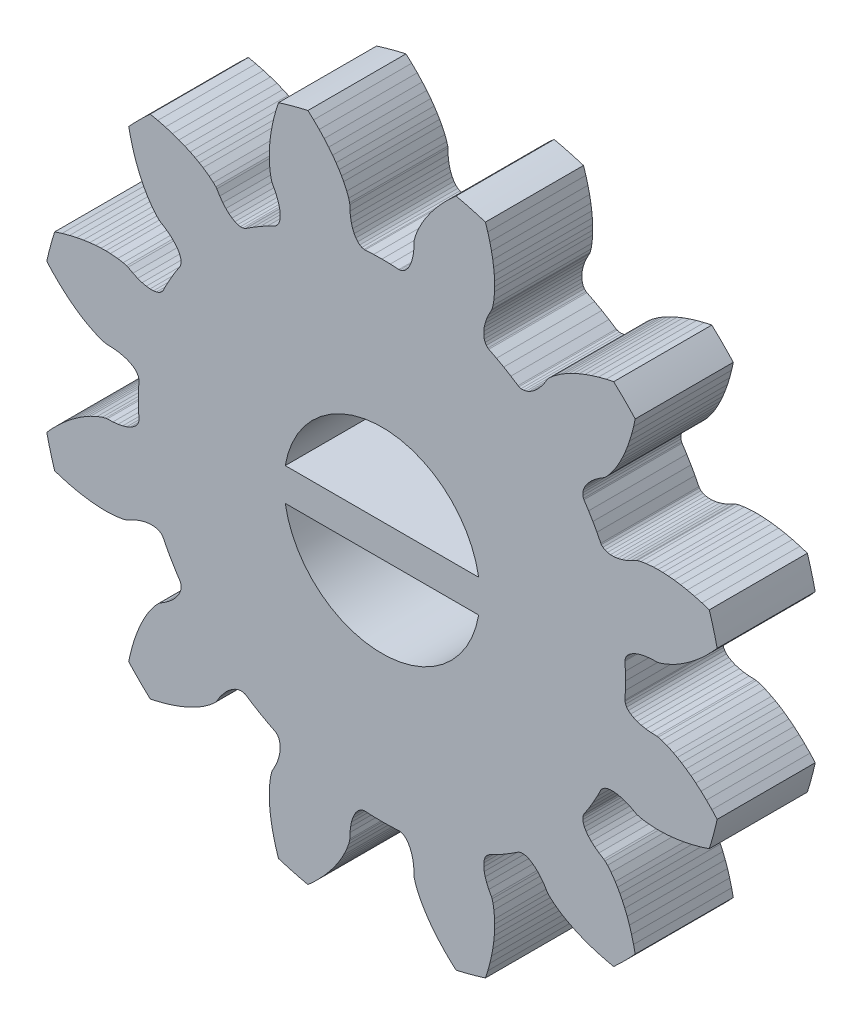
from build123d import *

# Parameters (mm, degrees)
DODANIE_WYCI_GNI_CIE1_DEPTH = 3


with BuildPart() as part:
    # szkic → Dodanie-wyciągnięcie1 (new body)
    with BuildSketch(Plane.XY):
        with BuildLine():
            Line((13.3041035, -6.8561363), (13.3646303, -6.6242917))
            Line((13.3646303, -6.6242917), (13.4304655, -6.4093816))
            Line((13.4304655, -6.4093816), (13.5002922, -6.2114851))
            Line((13.5002922, -6.2114851), (13.5727071, -6.0307313))
            Line((13.5727071, -6.0307313), (13.646359, -5.8670802))
            Line((13.646359, -5.8670802), (13.721124, -5.718017))
            Line((13.721124, -5.718017), (13.7934881, -5.5876952))
            Line((13.7934881, -5.5876952), (13.8641894, -5.4719934))
            Line((13.8641894, -5.4719934), (13.993399, -5.287051))
            Line((13.993399, -5.287051), (14.1005731, -5.157982))
            Line((14.1005731, -5.157982), (14.1765304, -5.080584))
            Line((14.1765304, -5.080584), (14.2152558, -5.0521983))
            Line((14.2152558, -5.0521983), (14.3621288, -4.9615699))
            Line((14.3621288, -4.9615699), (14.4896324, -4.8681526))
            Line((14.4896324, -4.8681526), (14.5978226, -4.7734035))
            Line((14.5978226, -4.7734035), (14.6868312, -4.6787708))
            Line((14.6868312, -4.6787708), (14.7568878, -4.5856924))
            Line((14.7568878, -4.5856924), (14.8083, -4.495561))
            Line((14.8083, -4.495561), (14.8414711, -4.409795))
            Line((14.8414711, -4.409795), (14.8568795, -4.3297232))
            Line((14.8568795, -4.3297232), (14.8550807, -4.2566876))
            Line((14.8550807, -4.2566876), (14.8367255, -4.1919755))
            Line((14.8367255, -4.1919755), (14.821549, -4.163129))
            Line((14.821549, -4.163129), (14.6787997, -3.9427598))
            Line((14.6787997, -3.9427598), (14.5481107, -3.725))
            Line((14.5481107, -3.725), (14.4248697, -3.5029402))
            Line((14.4248697, -3.5029402), (14.305399, -3.269131))
            Line((14.305399, -3.269131), (14.2880055, -3.2415645))
            Line((14.2880055, -3.2415645), (14.2411407, -3.1933124))
            Line((14.2411407, -3.1933124), (14.1787895, -3.1552368))
            Line((14.1787895, -3.1552368), (14.1017411, -3.128545))
            Line((14.1017411, -3.128545), (14.01088, -3.114389))
            Line((14.01088, -3.114389), (13.9071178, -3.1138476))
            Line((13.9071178, -3.1138476), (13.7914812, -3.1279792))
            Line((13.7914812, -3.1279792), (13.6650226, -3.1577465))
            Line((13.6650226, -3.1577465), (13.5288724, -3.2040674))
            Line((13.5288724, -3.2040674), (13.3842188, -3.2677801))
            Line((13.3842188, -3.2677801), (13.2322958, -3.3496617))
            Line((13.2322958, -3.3496617), (13.1883504, -3.369006))
            Line((13.1883504, -3.369006), (13.0833431, -3.396088))
            Line((13.0833431, -3.396088), (12.917979, -3.424369))
            Line((12.917979, -3.424369), (12.6932094, -3.4437966))
            Line((12.6932094, -3.4437966), (12.5576581, -3.4471748))
            Line((12.5576581, -3.4471748), (12.408614, -3.444683))
            Line((12.408614, -3.444683), (12.242139, -3.4348998))
            Line((12.242139, -3.4348998), (12.0635871, -3.4168587))
            Line((12.0635871, -3.4168587), (11.8708422, -3.3891949))
            Line((11.8708422, -3.3891949), (11.6645455, -3.3507184))
            Line((11.6645455, -3.3507184), (11.4455103, -3.3002783))
            Line((11.4455103, -3.3002783), (11.2144635, -3.2367737))
            Line((11.2144635, -3.2367737), (10.9882086, -3.1643386))
            ThreePointArc((10.9882086, -3.1643386), (10.857824593, -2.717587715), (10.747365, -2.2654981))
            Line((10.747365, -2.2654981), (10.90709, -2.08964))
            Line((10.90709, -2.08964), (11.07543, -1.91912))
            Line((11.07543, -1.91912), (11.2399, -1.76592))
            Line((11.2399, -1.76592), (11.39932, -1.62945))
            Line((11.39932, -1.62945), (11.55241, -1.50912))
            Line((11.55241, -1.50912), (11.69802, -1.40422))
            Line((11.69802, -1.40422), (11.8373, -1.31251))
            Line((11.8373, -1.31251), (11.96513, -1.23583))
            Line((11.96513, -1.23583), (12.08421, -1.17098))
            Line((12.08421, -1.17098), (12.28858, -1.07542))
            Line((12.28858, -1.07542), (12.44593, -1.01723))
            Line((12.44593, -1.01723), (12.55041, -0.98818))
            Line((12.55041, -0.98818), (12.59814, -0.98296))
            Line((12.59814, -0.98296), (12.77065, -0.97791))
            Line((12.77065, -0.97791), (12.92778, -0.96076))
            Line((12.92778, -0.96076), (13.06885, -0.9328))
            Line((13.06885, -0.9328), (13.19325, -0.89535))
            Line((13.19325, -0.89535), (13.30046, -0.84977))
            Line((13.30046, -0.84977), (13.39005, -0.79742))
            Line((13.39005, -0.79742), (13.46166, -0.73973))
            Line((13.46166, -0.73973), (13.51504, -0.67809))
            Line((13.51504, -0.67809), (13.55, -0.61394))
            Line((13.55, -0.61394), (13.56646, -0.54872))
            Line((13.56646, -0.54872), (13.56774, -0.51615))
            Line((13.56774, -0.51615), (13.5543, -0.25393))
            Line((13.5543, -0.25393), (13.55, 0))
            Line((13.55, 0), (13.5543, 0.25393))
            Line((13.5543, 0.25393), (13.56774, 0.51615))
            Line((13.56774, 0.51615), (13.56646, 0.54872))
            Line((13.56646, 0.54872), (13.55, 0.61394))
            Line((13.55, 0.61394), (13.51504, 0.67809))
            Line((13.51504, 0.67809), (13.46166, 0.73973))
            Line((13.46166, 0.73973), (13.39005, 0.79742))
            Line((13.39005, 0.79742), (13.30046, 0.84977))
            Line((13.30046, 0.84977), (13.19325, 0.89535))
            Line((13.19325, 0.89535), (13.06885, 0.9328))
            Line((13.06885, 0.9328), (12.92778, 0.96076))
            Line((12.92778, 0.96076), (12.77065, 0.97791))
            Line((12.77065, 0.97791), (12.59814, 0.98296))
            Line((12.59814, 0.98296), (12.55041, 0.98818))
            Line((12.55041, 0.98818), (12.44593, 1.01723))
            Line((12.44593, 1.01723), (12.28858, 1.07542))
            Line((12.28858, 1.07542), (12.08421, 1.17098))
            Line((12.08421, 1.17098), (11.96513, 1.23583))
            Line((11.96513, 1.23583), (11.8373, 1.31251))
            Line((11.8373, 1.31251), (11.69802, 1.40422))
            Line((11.69802, 1.40422), (11.55241, 1.50912))
            Line((11.55241, 1.50912), (11.39932, 1.62945))
            Line((11.39932, 1.62945), (11.2399, 1.76592))
            Line((11.2399, 1.76592), (11.07543, 1.91912))
            Line((11.07543, 1.91912), (10.90709, 2.08964))
            Line((10.90709, 2.08964), (10.747365, 2.2654981))
            ThreePointArc((10.747365, 2.2654981), (10.857824593, 2.717587715), (10.9882086, 3.1643386))
            Line((10.9882086, 3.1643386), (11.2144635, 3.2367737))
            Line((11.2144635, 3.2367737), (11.4455103, 3.3002783))
            Line((11.4455103, 3.3002783), (11.6645455, 3.3507184))
            Line((11.6645455, 3.3507184), (11.8708422, 3.3891949))
            Line((11.8708422, 3.3891949), (12.0635871, 3.4168587))
            Line((12.0635871, 3.4168587), (12.242139, 3.4348998))
            Line((12.242139, 3.4348998), (12.408614, 3.444683))
            Line((12.408614, 3.444683), (12.5576581, 3.4471748))
            Line((12.5576581, 3.4471748), (12.6932094, 3.4437966))
            Line((12.6932094, 3.4437966), (12.917979, 3.424369))
            Line((12.917979, 3.424369), (13.0833431, 3.396088))
            Line((13.0833431, 3.396088), (13.1883504, 3.369006))
            Line((13.1883504, 3.369006), (13.2322958, 3.3496617))
            Line((13.2322958, 3.3496617), (13.3842188, 3.2677801))
            Line((13.3842188, 3.2677801), (13.5288724, 3.2040674))
            Line((13.5288724, 3.2040674), (13.6650226, 3.1577465))
            Line((13.6650226, 3.1577465), (13.7914812, 3.1279792))
            Line((13.7914812, 3.1279792), (13.9071178, 3.1138476))
            Line((13.9071178, 3.1138476), (14.01088, 3.114389))
            Line((14.01088, 3.114389), (14.1017411, 3.128545))
            Line((14.1017411, 3.128545), (14.1787895, 3.1552368))
            Line((14.1787895, 3.1552368), (14.2411407, 3.1933124))
            Line((14.2411407, 3.1933124), (14.2880055, 3.2415645))
            Line((14.2880055, 3.2415645), (14.305399, 3.269131))
            Line((14.305399, 3.269131), (14.4248697, 3.5029402))
            Line((14.4248697, 3.5029402), (14.5481107, 3.725))
            Line((14.5481107, 3.725), (14.6787997, 3.9427598))
            Line((14.6787997, 3.9427598), (14.821549, 4.163129))
            Line((14.821549, 4.163129), (14.8367255, 4.1919755))
            Line((14.8367255, 4.1919755), (14.8550807, 4.2566876))
            Line((14.8550807, 4.2566876), (14.8568795, 4.3297232))
            Line((14.8568795, 4.3297232), (14.8414711, 4.409795))
            Line((14.8414711, 4.409795), (14.8083, 4.495561))
            Line((14.8083, 4.495561), (14.7568878, 4.5856924))
            Line((14.7568878, 4.5856924), (14.6868312, 4.6787708))
            Line((14.6868312, 4.6787708), (14.5978226, 4.7734035))
            Line((14.5978226, 4.7734035), (14.4896324, 4.8681526))
            Line((14.4896324, 4.8681526), (14.3621288, 4.9615699))
            Line((14.3621288, 4.9615699), (14.2152558, 5.0521983))
            Line((14.2152558, 5.0521983), (14.1765304, 5.080584))
            Line((14.1765304, 5.080584), (14.1005731, 5.157982))
            Line((14.1005731, 5.157982), (13.993399, 5.287051))
            Line((13.993399, 5.287051), (13.8641894, 5.4719934))
            Line((13.8641894, 5.4719934), (13.7934881, 5.5876952))
            Line((13.7934881, 5.5876952), (13.721124, 5.718017))
            Line((13.721124, 5.718017), (13.646359, 5.8670802))
            Line((13.646359, 5.8670802), (13.5727071, 6.0307313))
            Line((13.5727071, 6.0307313), (13.5002922, 6.2114851))
            Line((13.5002922, 6.2114851), (13.4304655, 6.4093816))
            Line((13.4304655, 6.4093816), (13.3646303, 6.6242917))
            Line((13.3646303, 6.6242917), (13.3041035, 6.8561363))
            Line((13.3041035, 6.8561363), (13.2537067, 7.0882964))
            ThreePointArc((13.2537067, 7.0882964), (13.575412309, 7.424587691), (13.9117036, 7.7462933))
            Line((13.9117036, 7.7462933), (14.1438637, 7.6958965))
            Line((14.1438637, 7.6958965), (14.3757083, 7.6353697))
            Line((14.3757083, 7.6353697), (14.5906184, 7.5695345))
            Line((14.5906184, 7.5695345), (14.7885149, 7.4997078))
            Line((14.7885149, 7.4997078), (14.9692687, 7.4272929))
            Line((14.9692687, 7.4272929), (15.1329198, 7.353641))
            Line((15.1329198, 7.353641), (15.281983, 7.278876))
            Line((15.281983, 7.278876), (15.4123048, 7.2065119))
            Line((15.4123048, 7.2065119), (15.5280066, 7.1358106))
            Line((15.5280066, 7.1358106), (15.712949, 7.006601))
            Line((15.712949, 7.006601), (15.842018, 6.8994269))
            Line((15.842018, 6.8994269), (15.919416, 6.8234696))
            Line((15.919416, 6.8234696), (15.9478017, 6.7847442))
            Line((15.9478017, 6.7847442), (16.0384301, 6.6378712))
            Line((16.0384301, 6.6378712), (16.1318474, 6.5103676))
            Line((16.1318474, 6.5103676), (16.2265965, 6.4021774))
            Line((16.2265965, 6.4021774), (16.3212292, 6.3131688))
            Line((16.3212292, 6.3131688), (16.4143076, 6.2431122))
            Line((16.4143076, 6.2431122), (16.504439, 6.1917))
            Line((16.504439, 6.1917), (16.590205, 6.1585289))
            Line((16.590205, 6.1585289), (16.6702768, 6.1431205))
            Line((16.6702768, 6.1431205), (16.7433124, 6.1449193))
            Line((16.7433124, 6.1449193), (16.8080245, 6.1632745))
            Line((16.8080245, 6.1632745), (16.836871, 6.178451))
            Line((16.836871, 6.178451), (17.0572402, 6.3212003))
            Line((17.0572402, 6.3212003), (17.275, 6.4518893))
            Line((17.275, 6.4518893), (17.4970598, 6.5751303))
            Line((17.4970598, 6.5751303), (17.730869, 6.694601))
            Line((17.730869, 6.694601), (17.7584355, 6.7119945))
            Line((17.7584355, 6.7119945), (17.8066876, 6.7588593))
            Line((17.8066876, 6.7588593), (17.8447632, 6.8212105))
            Line((17.8447632, 6.8212105), (17.871455, 6.8982589))
            Line((17.871455, 6.8982589), (17.885611, 6.98912))
            Line((17.885611, 6.98912), (17.8861524, 7.0928822))
            Line((17.8861524, 7.0928822), (17.8720208, 7.2085188))
            Line((17.8720208, 7.2085188), (17.8422535, 7.3349774))
            Line((17.8422535, 7.3349774), (17.7959326, 7.4711276))
            Line((17.7959326, 7.4711276), (17.7322199, 7.6157812))
            Line((17.7322199, 7.6157812), (17.6503383, 7.7677042))
            Line((17.6503383, 7.7677042), (17.630994, 7.8116496))
            Line((17.630994, 7.8116496), (17.603912, 7.9166569))
            Line((17.603912, 7.9166569), (17.575631, 8.082021))
            Line((17.575631, 8.082021), (17.5562034, 8.3067906))
            Line((17.5562034, 8.3067906), (17.5528252, 8.4423419))
            Line((17.5528252, 8.4423419), (17.555317, 8.591386))
            Line((17.555317, 8.591386), (17.5651002, 8.757861))
            Line((17.5651002, 8.757861), (17.5831413, 8.9364129))
            Line((17.5831413, 8.9364129), (17.6108051, 9.1291578))
            Line((17.6108051, 9.1291578), (17.6492816, 9.3354545))
            Line((17.6492816, 9.3354545), (17.6997217, 9.5544897))
            Line((17.6997217, 9.5544897), (17.7632263, 9.7855365))
            Line((17.7632263, 9.7855365), (17.8356614, 10.0117914))
            ThreePointArc((17.8356614, 10.0117914), (18.282412285, 10.142175407), (18.7345019, 10.252635))
            Line((18.7345019, 10.252635), (18.91036, 10.09291))
            Line((18.91036, 10.09291), (19.08088, 9.92457))
            Line((19.08088, 9.92457), (19.23408, 9.7601))
            Line((19.23408, 9.7601), (19.37055, 9.60068))
            Line((19.37055, 9.60068), (19.49088, 9.44759))
            Line((19.49088, 9.44759), (19.59578, 9.30198))
            Line((19.59578, 9.30198), (19.68749, 9.1627))
            Line((19.68749, 9.1627), (19.76417, 9.03487))
            Line((19.76417, 9.03487), (19.82902, 8.91579))
            Line((19.82902, 8.91579), (19.92458, 8.71142))
            Line((19.92458, 8.71142), (19.98277, 8.55407))
            Line((19.98277, 8.55407), (20.01182, 8.44959))
            Line((20.01182, 8.44959), (20.01704, 8.40186))
            Line((20.01704, 8.40186), (20.02209, 8.22935))
            Line((20.02209, 8.22935), (20.03924, 8.07222))
            Line((20.03924, 8.07222), (20.0672, 7.93115))
            Line((20.0672, 7.93115), (20.10465, 7.80675))
            Line((20.10465, 7.80675), (20.15023, 7.69954))
            Line((20.15023, 7.69954), (20.20258, 7.60995))
            Line((20.20258, 7.60995), (20.26027, 7.53834))
            Line((20.26027, 7.53834), (20.32191, 7.48496))
            Line((20.32191, 7.48496), (20.38606, 7.45))
            Line((20.38606, 7.45), (20.45128, 7.43354))
            Line((20.45128, 7.43354), (20.48385, 7.43226))
            Line((20.48385, 7.43226), (20.74607, 7.4457))
            Line((20.74607, 7.4457), (21, 7.45))
            Line((21, 7.45), (21.25393, 7.4457))
            Line((21.25393, 7.4457), (21.51615, 7.43226))
            Line((21.51615, 7.43226), (21.54872, 7.43354))
            Line((21.54872, 7.43354), (21.61394, 7.45))
            Line((21.61394, 7.45), (21.67809, 7.48496))
            Line((21.67809, 7.48496), (21.73973, 7.53834))
            Line((21.73973, 7.53834), (21.79742, 7.60995))
            Line((21.79742, 7.60995), (21.84977, 7.69954))
            Line((21.84977, 7.69954), (21.89535, 7.80675))
            Line((21.89535, 7.80675), (21.9328, 7.93115))
            Line((21.9328, 7.93115), (21.96076, 8.07222))
            Line((21.96076, 8.07222), (21.97791, 8.22935))
            Line((21.97791, 8.22935), (21.98296, 8.40186))
            Line((21.98296, 8.40186), (21.98818, 8.44959))
            Line((21.98818, 8.44959), (22.01723, 8.55407))
            Line((22.01723, 8.55407), (22.07542, 8.71142))
            Line((22.07542, 8.71142), (22.17098, 8.91579))
            Line((22.17098, 8.91579), (22.23583, 9.03487))
            Line((22.23583, 9.03487), (22.31251, 9.1627))
            Line((22.31251, 9.1627), (22.40422, 9.30198))
            Line((22.40422, 9.30198), (22.50912, 9.44759))
            Line((22.50912, 9.44759), (22.62945, 9.60068))
            Line((22.62945, 9.60068), (22.76592, 9.7601))
            Line((22.76592, 9.7601), (22.91912, 9.92457))
            Line((22.91912, 9.92457), (23.08964, 10.09291))
            Line((23.08964, 10.09291), (23.2654981, 10.252635))
            ThreePointArc((23.2654981, 10.252635), (23.717587715, 10.142175407), (24.1643386, 10.0117914))
            Line((24.1643386, 10.0117914), (24.2367737, 9.7855365))
            Line((24.2367737, 9.7855365), (24.3002783, 9.5544897))
            Line((24.3002783, 9.5544897), (24.3507184, 9.3354545))
            Line((24.3507184, 9.3354545), (24.3891949, 9.1291578))
            Line((24.3891949, 9.1291578), (24.4168587, 8.9364129))
            Line((24.4168587, 8.9364129), (24.4348998, 8.757861))
            Line((24.4348998, 8.757861), (24.444683, 8.591386))
            Line((24.444683, 8.591386), (24.4471748, 8.4423419))
            Line((24.4471748, 8.4423419), (24.4437966, 8.3067906))
            Line((24.4437966, 8.3067906), (24.424369, 8.082021))
            Line((24.424369, 8.082021), (24.396088, 7.9166569))
            Line((24.396088, 7.9166569), (24.369006, 7.8116496))
            Line((24.369006, 7.8116496), (24.3496617, 7.7677042))
            Line((24.3496617, 7.7677042), (24.2677801, 7.6157812))
            Line((24.2677801, 7.6157812), (24.2040674, 7.4711276))
            Line((24.2040674, 7.4711276), (24.1577465, 7.3349774))
            Line((24.1577465, 7.3349774), (24.1279792, 7.2085188))
            Line((24.1279792, 7.2085188), (24.1138476, 7.0928822))
            Line((24.1138476, 7.0928822), (24.114389, 6.98912))
            Line((24.114389, 6.98912), (24.128545, 6.8982589))
            Line((24.128545, 6.8982589), (24.1552368, 6.8212105))
            Line((24.1552368, 6.8212105), (24.1933124, 6.7588593))
            Line((24.1933124, 6.7588593), (24.2415645, 6.7119945))
            Line((24.2415645, 6.7119945), (24.269131, 6.694601))
            Line((24.269131, 6.694601), (24.5029402, 6.5751303))
            Line((24.5029402, 6.5751303), (24.725, 6.4518893))
            Line((24.725, 6.4518893), (24.9427598, 6.3212003))
            Line((24.9427598, 6.3212003), (25.163129, 6.178451))
            Line((25.163129, 6.178451), (25.1919755, 6.1632745))
            Line((25.1919755, 6.1632745), (25.2566876, 6.1449193))
            Line((25.2566876, 6.1449193), (25.3297232, 6.1431205))
            Line((25.3297232, 6.1431205), (25.409795, 6.1585289))
            Line((25.409795, 6.1585289), (25.495561, 6.1917))
            Line((25.495561, 6.1917), (25.5856924, 6.2431122))
            Line((25.5856924, 6.2431122), (25.6787708, 6.3131688))
            Line((25.6787708, 6.3131688), (25.7734035, 6.4021774))
            Line((25.7734035, 6.4021774), (25.8681526, 6.5103676))
            Line((25.8681526, 6.5103676), (25.9615699, 6.6378712))
            Line((25.9615699, 6.6378712), (26.0521983, 6.7847442))
            Line((26.0521983, 6.7847442), (26.080584, 6.8234696))
            Line((26.080584, 6.8234696), (26.157982, 6.8994269))
            Line((26.157982, 6.8994269), (26.287051, 7.006601))
            Line((26.287051, 7.006601), (26.4719934, 7.1358106))
            Line((26.4719934, 7.1358106), (26.5876952, 7.2065119))
            Line((26.5876952, 7.2065119), (26.718017, 7.278876))
            Line((26.718017, 7.278876), (26.8670802, 7.353641))
            Line((26.8670802, 7.353641), (27.0307313, 7.4272929))
            Line((27.0307313, 7.4272929), (27.2114851, 7.4997078))
            Line((27.2114851, 7.4997078), (27.4093816, 7.5695345))
            Line((27.4093816, 7.5695345), (27.6242917, 7.6353697))
            Line((27.6242917, 7.6353697), (27.8561363, 7.6958965))
            Line((27.8561363, 7.6958965), (28.0882964, 7.7462933))
            ThreePointArc((28.0882964, 7.7462933), (28.424587691, 7.424587691), (28.7462933, 7.0882964))
            Line((28.7462933, 7.0882964), (28.6958965, 6.8561363))
            Line((28.6958965, 6.8561363), (28.6353697, 6.6242917))
            Line((28.6353697, 6.6242917), (28.5695345, 6.4093816))
            Line((28.5695345, 6.4093816), (28.4997078, 6.2114851))
            Line((28.4997078, 6.2114851), (28.4272929, 6.0307313))
            Line((28.4272929, 6.0307313), (28.353641, 5.8670802))
            Line((28.353641, 5.8670802), (28.278876, 5.718017))
            Line((28.278876, 5.718017), (28.2065119, 5.5876952))
            Line((28.2065119, 5.5876952), (28.1358106, 5.4719934))
            Line((28.1358106, 5.4719934), (28.006601, 5.287051))
            Line((28.006601, 5.287051), (27.8994269, 5.157982))
            Line((27.8994269, 5.157982), (27.8234696, 5.080584))
            Line((27.8234696, 5.080584), (27.7847442, 5.0521983))
            Line((27.7847442, 5.0521983), (27.6378712, 4.9615699))
            Line((27.6378712, 4.9615699), (27.5103676, 4.8681526))
            Line((27.5103676, 4.8681526), (27.4021774, 4.7734035))
            Line((27.4021774, 4.7734035), (27.3131688, 4.6787708))
            Line((27.3131688, 4.6787708), (27.2431122, 4.5856924))
            Line((27.2431122, 4.5856924), (27.1917, 4.495561))
            Line((27.1917, 4.495561), (27.1585289, 4.409795))
            Line((27.1585289, 4.409795), (27.1431205, 4.3297232))
            Line((27.1431205, 4.3297232), (27.1449193, 4.2566876))
            Line((27.1449193, 4.2566876), (27.1632745, 4.1919755))
            Line((27.1632745, 4.1919755), (27.178451, 4.163129))
            Line((27.178451, 4.163129), (27.3212003, 3.9427598))
            Line((27.3212003, 3.9427598), (27.4518893, 3.725))
            Line((27.4518893, 3.725), (27.5751303, 3.5029402))
            Line((27.5751303, 3.5029402), (27.694601, 3.269131))
            Line((27.694601, 3.269131), (27.7119945, 3.2415645))
            Line((27.7119945, 3.2415645), (27.7588593, 3.1933124))
            Line((27.7588593, 3.1933124), (27.8212105, 3.1552368))
            Line((27.8212105, 3.1552368), (27.8982589, 3.128545))
            Line((27.8982589, 3.128545), (27.98912, 3.114389))
            Line((27.98912, 3.114389), (28.0928822, 3.1138476))
            Line((28.0928822, 3.1138476), (28.2085188, 3.1279792))
            Line((28.2085188, 3.1279792), (28.3349774, 3.1577465))
            Line((28.3349774, 3.1577465), (28.4711276, 3.2040674))
            Line((28.4711276, 3.2040674), (28.6157812, 3.2677801))
            Line((28.6157812, 3.2677801), (28.7677042, 3.3496617))
            Line((28.7677042, 3.3496617), (28.8116496, 3.369006))
            Line((28.8116496, 3.369006), (28.9166569, 3.396088))
            Line((28.9166569, 3.396088), (29.082021, 3.424369))
            Line((29.082021, 3.424369), (29.3067906, 3.4437966))
            Line((29.3067906, 3.4437966), (29.4423419, 3.4471748))
            Line((29.4423419, 3.4471748), (29.591386, 3.444683))
            Line((29.591386, 3.444683), (29.757861, 3.4348998))
            Line((29.757861, 3.4348998), (29.9364129, 3.4168587))
            Line((29.9364129, 3.4168587), (30.1291578, 3.3891949))
            Line((30.1291578, 3.3891949), (30.3354545, 3.3507184))
            Line((30.3354545, 3.3507184), (30.5544897, 3.3002783))
            Line((30.5544897, 3.3002783), (30.7855365, 3.2367737))
            Line((30.7855365, 3.2367737), (31.0117914, 3.1643386))
            ThreePointArc((31.0117914, 3.1643386), (31.142175407, 2.717587715), (31.252635, 2.2654981))
            Line((31.252635, 2.2654981), (31.09291, 2.08964))
            Line((31.09291, 2.08964), (30.92457, 1.91912))
            Line((30.92457, 1.91912), (30.7601, 1.76592))
            Line((30.7601, 1.76592), (30.60068, 1.62945))
            Line((30.60068, 1.62945), (30.44759, 1.50912))
            Line((30.44759, 1.50912), (30.30198, 1.40422))
            Line((30.30198, 1.40422), (30.1627, 1.31251))
            Line((30.1627, 1.31251), (30.03487, 1.23583))
            Line((30.03487, 1.23583), (29.91579, 1.17098))
            Line((29.91579, 1.17098), (29.71142, 1.07542))
            Line((29.71142, 1.07542), (29.55407, 1.01723))
            Line((29.55407, 1.01723), (29.44959, 0.98818))
            Line((29.44959, 0.98818), (29.40186, 0.98296))
            Line((29.40186, 0.98296), (29.22935, 0.97791))
            Line((29.22935, 0.97791), (29.07222, 0.96076))
            Line((29.07222, 0.96076), (28.93115, 0.9328))
            Line((28.93115, 0.9328), (28.80675, 0.89535))
            Line((28.80675, 0.89535), (28.69954, 0.84977))
            Line((28.69954, 0.84977), (28.60995, 0.79742))
            Line((28.60995, 0.79742), (28.53834, 0.73973))
            Line((28.53834, 0.73973), (28.48496, 0.67809))
            Line((28.48496, 0.67809), (28.45, 0.61394))
            Line((28.45, 0.61394), (28.43354, 0.54872))
            Line((28.43354, 0.54872), (28.43226, 0.51615))
            Line((28.43226, 0.51615), (28.4457, 0.25393))
            Line((28.4457, 0.25393), (28.45, 0))
            Line((28.45, 0), (28.4457, -0.25393))
            Line((28.4457, -0.25393), (28.43226, -0.51615))
            Line((28.43226, -0.51615), (28.43354, -0.54872))
            Line((28.43354, -0.54872), (28.45, -0.61394))
            Line((28.45, -0.61394), (28.48496, -0.67809))
            Line((28.48496, -0.67809), (28.53834, -0.73973))
            Line((28.53834, -0.73973), (28.60995, -0.79742))
            Line((28.60995, -0.79742), (28.69954, -0.84977))
            Line((28.69954, -0.84977), (28.80675, -0.89535))
            Line((28.80675, -0.89535), (28.93115, -0.9328))
            Line((28.93115, -0.9328), (29.07222, -0.96076))
            Line((29.07222, -0.96076), (29.22935, -0.97791))
            Line((29.22935, -0.97791), (29.40186, -0.98296))
            Line((29.40186, -0.98296), (29.44959, -0.98818))
            Line((29.44959, -0.98818), (29.55407, -1.01723))
            Line((29.55407, -1.01723), (29.71142, -1.07542))
            Line((29.71142, -1.07542), (29.91579, -1.17098))
            Line((29.91579, -1.17098), (30.03487, -1.23583))
            Line((30.03487, -1.23583), (30.1627, -1.31251))
            Line((30.1627, -1.31251), (30.30198, -1.40422))
            Line((30.30198, -1.40422), (30.44759, -1.50912))
            Line((30.44759, -1.50912), (30.60068, -1.62945))
            Line((30.60068, -1.62945), (30.7601, -1.76592))
            Line((30.7601, -1.76592), (30.92457, -1.91912))
            Line((30.92457, -1.91912), (31.09291, -2.08964))
            Line((31.09291, -2.08964), (31.252635, -2.2654981))
            ThreePointArc((31.252635, -2.2654981), (31.142175407, -2.717587715), (31.0117914, -3.1643386))
            Line((31.0117914, -3.1643386), (30.7855365, -3.2367737))
            Line((30.7855365, -3.2367737), (30.5544897, -3.3002783))
            Line((30.5544897, -3.3002783), (30.3354545, -3.3507184))
            Line((30.3354545, -3.3507184), (30.1291578, -3.3891949))
            Line((30.1291578, -3.3891949), (29.9364129, -3.4168587))
            Line((29.9364129, -3.4168587), (29.757861, -3.4348998))
            Line((29.757861, -3.4348998), (29.591386, -3.444683))
            Line((29.591386, -3.444683), (29.4423419, -3.4471748))
            Line((29.4423419, -3.4471748), (29.3067906, -3.4437966))
            Line((29.3067906, -3.4437966), (29.082021, -3.424369))
            Line((29.082021, -3.424369), (28.9166569, -3.396088))
            Line((28.9166569, -3.396088), (28.8116496, -3.369006))
            Line((28.8116496, -3.369006), (28.7677042, -3.3496617))
            Line((28.7677042, -3.3496617), (28.6157812, -3.2677801))
            Line((28.6157812, -3.2677801), (28.4711276, -3.2040674))
            Line((28.4711276, -3.2040674), (28.3349774, -3.1577465))
            Line((28.3349774, -3.1577465), (28.2085188, -3.1279792))
            Line((28.2085188, -3.1279792), (28.0928822, -3.1138476))
            Line((28.0928822, -3.1138476), (27.98912, -3.114389))
            Line((27.98912, -3.114389), (27.8982589, -3.128545))
            Line((27.8982589, -3.128545), (27.8212105, -3.1552368))
            Line((27.8212105, -3.1552368), (27.7588593, -3.1933124))
            Line((27.7588593, -3.1933124), (27.7119945, -3.2415645))
            Line((27.7119945, -3.2415645), (27.694601, -3.269131))
            Line((27.694601, -3.269131), (27.5751303, -3.5029402))
            Line((27.5751303, -3.5029402), (27.4518893, -3.725))
            Line((27.4518893, -3.725), (27.3212003, -3.9427598))
            Line((27.3212003, -3.9427598), (27.178451, -4.163129))
            Line((27.178451, -4.163129), (27.1632745, -4.1919755))
            Line((27.1632745, -4.1919755), (27.1449193, -4.2566876))
            Line((27.1449193, -4.2566876), (27.1431205, -4.3297232))
            Line((27.1431205, -4.3297232), (27.1585289, -4.409795))
            Line((27.1585289, -4.409795), (27.1917, -4.495561))
            Line((27.1917, -4.495561), (27.2431122, -4.5856924))
            Line((27.2431122, -4.5856924), (27.3131688, -4.6787708))
            Line((27.3131688, -4.6787708), (27.4021774, -4.7734035))
            Line((27.4021774, -4.7734035), (27.5103676, -4.8681526))
            Line((27.5103676, -4.8681526), (27.6378712, -4.9615699))
            Line((27.6378712, -4.9615699), (27.7847442, -5.0521983))
            Line((27.7847442, -5.0521983), (27.8234696, -5.080584))
            Line((27.8234696, -5.080584), (27.8994269, -5.157982))
            Line((27.8994269, -5.157982), (28.006601, -5.287051))
            Line((28.006601, -5.287051), (28.1358106, -5.4719934))
            Line((28.1358106, -5.4719934), (28.2065119, -5.5876952))
            Line((28.2065119, -5.5876952), (28.278876, -5.718017))
            Line((28.278876, -5.718017), (28.353641, -5.8670802))
            Line((28.353641, -5.8670802), (28.4272929, -6.0307313))
            Line((28.4272929, -6.0307313), (28.4997078, -6.2114851))
            Line((28.4997078, -6.2114851), (28.5695345, -6.4093816))
            Line((28.5695345, -6.4093816), (28.6353697, -6.6242917))
            Line((28.6353697, -6.6242917), (28.6958965, -6.8561363))
            Line((28.6958965, -6.8561363), (28.7462933, -7.0882964))
            ThreePointArc((28.7462933, -7.0882964), (28.424587691, -7.424587691), (28.0882964, -7.7462933))
            Line((28.0882964, -7.7462933), (27.8561363, -7.6958965))
            Line((27.8561363, -7.6958965), (27.6242917, -7.6353697))
            Line((27.6242917, -7.6353697), (27.4093816, -7.5695345))
            Line((27.4093816, -7.5695345), (27.2114851, -7.4997078))
            Line((27.2114851, -7.4997078), (27.0307313, -7.4272929))
            Line((27.0307313, -7.4272929), (26.8670802, -7.353641))
            Line((26.8670802, -7.353641), (26.718017, -7.278876))
            Line((26.718017, -7.278876), (26.5876952, -7.2065119))
            Line((26.5876952, -7.2065119), (26.4719934, -7.1358106))
            Line((26.4719934, -7.1358106), (26.287051, -7.006601))
            Line((26.287051, -7.006601), (26.157982, -6.8994269))
            Line((26.157982, -6.8994269), (26.080584, -6.8234696))
            Line((26.080584, -6.8234696), (26.0521983, -6.7847442))
            Line((26.0521983, -6.7847442), (25.9615699, -6.6378712))
            Line((25.9615699, -6.6378712), (25.8681526, -6.5103676))
            Line((25.8681526, -6.5103676), (25.7734035, -6.4021774))
            Line((25.7734035, -6.4021774), (25.6787708, -6.3131688))
            Line((25.6787708, -6.3131688), (25.5856924, -6.2431122))
            Line((25.5856924, -6.2431122), (25.495561, -6.1917))
            Line((25.495561, -6.1917), (25.409795, -6.1585289))
            Line((25.409795, -6.1585289), (25.3297232, -6.1431205))
            Line((25.3297232, -6.1431205), (25.2566876, -6.1449193))
            Line((25.2566876, -6.1449193), (25.1919755, -6.1632745))
            Line((25.1919755, -6.1632745), (25.163129, -6.178451))
            Line((25.163129, -6.178451), (24.9427598, -6.3212003))
            Line((24.9427598, -6.3212003), (24.725, -6.4518893))
            Line((24.725, -6.4518893), (24.5029402, -6.5751303))
            Line((24.5029402, -6.5751303), (24.269131, -6.694601))
            Line((24.269131, -6.694601), (24.2415645, -6.7119945))
            Line((24.2415645, -6.7119945), (24.1933124, -6.7588593))
            Line((24.1933124, -6.7588593), (24.1552368, -6.8212105))
            Line((24.1552368, -6.8212105), (24.128545, -6.8982589))
            Line((24.128545, -6.8982589), (24.114389, -6.98912))
            Line((24.114389, -6.98912), (24.1138476, -7.0928822))
            Line((24.1138476, -7.0928822), (24.1279792, -7.2085188))
            Line((24.1279792, -7.2085188), (24.1577465, -7.3349774))
            Line((24.1577465, -7.3349774), (24.2040674, -7.4711276))
            Line((24.2040674, -7.4711276), (24.2677801, -7.6157812))
            Line((24.2677801, -7.6157812), (24.3496617, -7.7677042))
            Line((24.3496617, -7.7677042), (24.369006, -7.8116496))
            Line((24.369006, -7.8116496), (24.396088, -7.9166569))
            Line((24.396088, -7.9166569), (24.424369, -8.082021))
            Line((24.424369, -8.082021), (24.4437966, -8.3067906))
            Line((24.4437966, -8.3067906), (24.4471748, -8.4423419))
            Line((24.4471748, -8.4423419), (24.444683, -8.591386))
            Line((24.444683, -8.591386), (24.4348998, -8.757861))
            Line((24.4348998, -8.757861), (24.4168587, -8.9364129))
            Line((24.4168587, -8.9364129), (24.3891949, -9.1291578))
            Line((24.3891949, -9.1291578), (24.3507184, -9.3354545))
            Line((24.3507184, -9.3354545), (24.3002783, -9.5544897))
            Line((24.3002783, -9.5544897), (24.2367737, -9.7855365))
            Line((24.2367737, -9.7855365), (24.1643386, -10.0117914))
            ThreePointArc((24.1643386, -10.0117914), (23.717587715, -10.142175407), (23.2654981, -10.252635))
            Line((23.2654981, -10.252635), (23.08964, -10.09291))
            Line((23.08964, -10.09291), (22.91912, -9.92457))
            Line((22.91912, -9.92457), (22.76592, -9.7601))
            Line((22.76592, -9.7601), (22.62945, -9.60068))
            Line((22.62945, -9.60068), (22.50912, -9.44759))
            Line((22.50912, -9.44759), (22.40422, -9.30198))
            Line((22.40422, -9.30198), (22.31251, -9.1627))
            Line((22.31251, -9.1627), (22.23583, -9.03487))
            Line((22.23583, -9.03487), (22.17098, -8.91579))
            Line((22.17098, -8.91579), (22.07542, -8.71142))
            Line((22.07542, -8.71142), (22.01723, -8.55407))
            Line((22.01723, -8.55407), (21.98818, -8.44959))
            Line((21.98818, -8.44959), (21.98296, -8.40186))
            Line((21.98296, -8.40186), (21.97791, -8.22935))
            Line((21.97791, -8.22935), (21.96076, -8.07222))
            Line((21.96076, -8.07222), (21.9328, -7.93115))
            Line((21.9328, -7.93115), (21.89535, -7.80675))
            Line((21.89535, -7.80675), (21.84977, -7.69954))
            Line((21.84977, -7.69954), (21.79742, -7.60995))
            Line((21.79742, -7.60995), (21.73973, -7.53834))
            Line((21.73973, -7.53834), (21.67809, -7.48496))
            Line((21.67809, -7.48496), (21.61394, -7.45))
            Line((21.61394, -7.45), (21.54872, -7.43354))
            Line((21.54872, -7.43354), (21.51615, -7.43226))
            Line((21.51615, -7.43226), (21.25393, -7.4457))
            Line((21.25393, -7.4457), (21, -7.45))
            Line((21, -7.45), (20.74607, -7.4457))
            Line((20.74607, -7.4457), (20.48385, -7.43226))
            Line((20.48385, -7.43226), (20.45128, -7.43354))
            Line((20.45128, -7.43354), (20.38606, -7.45))
            Line((20.38606, -7.45), (20.32191, -7.48496))
            Line((20.32191, -7.48496), (20.26027, -7.53834))
            Line((20.26027, -7.53834), (20.20258, -7.60995))
            Line((20.20258, -7.60995), (20.15023, -7.69954))
            Line((20.15023, -7.69954), (20.10465, -7.80675))
            Line((20.10465, -7.80675), (20.0672, -7.93115))
            Line((20.0672, -7.93115), (20.03924, -8.07222))
            Line((20.03924, -8.07222), (20.02209, -8.22935))
            Line((20.02209, -8.22935), (20.01704, -8.40186))
            Line((20.01704, -8.40186), (20.01182, -8.44959))
            Line((20.01182, -8.44959), (19.98277, -8.55407))
            Line((19.98277, -8.55407), (19.92458, -8.71142))
            Line((19.92458, -8.71142), (19.82902, -8.91579))
            Line((19.82902, -8.91579), (19.76417, -9.03487))
            Line((19.76417, -9.03487), (19.68749, -9.1627))
            Line((19.68749, -9.1627), (19.59578, -9.30198))
            Line((19.59578, -9.30198), (19.49088, -9.44759))
            Line((19.49088, -9.44759), (19.37055, -9.60068))
            Line((19.37055, -9.60068), (19.23408, -9.7601))
            Line((19.23408, -9.7601), (19.08088, -9.92457))
            Line((19.08088, -9.92457), (18.91036, -10.09291))
            Line((18.91036, -10.09291), (18.7345019, -10.252635))
            ThreePointArc((18.7345019, -10.252635), (18.282412285, -10.142175407), (17.8356614, -10.0117914))
            Line((17.8356614, -10.0117914), (17.7632263, -9.7855365))
            Line((17.7632263, -9.7855365), (17.6997217, -9.5544897))
            Line((17.6997217, -9.5544897), (17.6492816, -9.3354545))
            Line((17.6492816, -9.3354545), (17.6108051, -9.1291578))
            Line((17.6108051, -9.1291578), (17.5831413, -8.9364129))
            Line((17.5831413, -8.9364129), (17.5651002, -8.757861))
            Line((17.5651002, -8.757861), (17.555317, -8.591386))
            Line((17.555317, -8.591386), (17.5528252, -8.4423419))
            Line((17.5528252, -8.4423419), (17.5562034, -8.3067906))
            Line((17.5562034, -8.3067906), (17.575631, -8.082021))
            Line((17.575631, -8.082021), (17.603912, -7.9166569))
            Line((17.603912, -7.9166569), (17.630994, -7.8116496))
            Line((17.630994, -7.8116496), (17.6503383, -7.7677042))
            Line((17.6503383, -7.7677042), (17.7322199, -7.6157812))
            Line((17.7322199, -7.6157812), (17.7959326, -7.4711276))
            Line((17.7959326, -7.4711276), (17.8422535, -7.3349774))
            Line((17.8422535, -7.3349774), (17.8720208, -7.2085188))
            Line((17.8720208, -7.2085188), (17.8861524, -7.0928822))
            Line((17.8861524, -7.0928822), (17.885611, -6.98912))
            Line((17.885611, -6.98912), (17.871455, -6.8982589))
            Line((17.871455, -6.8982589), (17.8447632, -6.8212105))
            Line((17.8447632, -6.8212105), (17.8066876, -6.7588593))
            Line((17.8066876, -6.7588593), (17.7584355, -6.7119945))
            Line((17.7584355, -6.7119945), (17.730869, -6.694601))
            Line((17.730869, -6.694601), (17.4970598, -6.5751303))
            Line((17.4970598, -6.5751303), (17.275, -6.4518893))
            Line((17.275, -6.4518893), (17.0572402, -6.3212003))
            Line((17.0572402, -6.3212003), (16.836871, -6.178451))
            Line((16.836871, -6.178451), (16.8080245, -6.1632745))
            Line((16.8080245, -6.1632745), (16.7433124, -6.1449193))
            Line((16.7433124, -6.1449193), (16.6702768, -6.1431205))
            Line((16.6702768, -6.1431205), (16.590205, -6.1585289))
            Line((16.590205, -6.1585289), (16.504439, -6.1917))
            Line((16.504439, -6.1917), (16.4143076, -6.2431122))
            Line((16.4143076, -6.2431122), (16.3212292, -6.3131688))
            Line((16.3212292, -6.3131688), (16.2265965, -6.4021774))
            Line((16.2265965, -6.4021774), (16.1318474, -6.5103676))
            Line((16.1318474, -6.5103676), (16.0384301, -6.6378712))
            Line((16.0384301, -6.6378712), (15.9478017, -6.7847442))
            Line((15.9478017, -6.7847442), (15.919416, -6.8234696))
            Line((15.919416, -6.8234696), (15.842018, -6.8994269))
            Line((15.842018, -6.8994269), (15.712949, -7.006601))
            Line((15.712949, -7.006601), (15.5280066, -7.1358106))
            Line((15.5280066, -7.1358106), (15.4123048, -7.2065119))
            Line((15.4123048, -7.2065119), (15.281983, -7.278876))
            Line((15.281983, -7.278876), (15.1329198, -7.353641))
            Line((15.1329198, -7.353641), (14.9692687, -7.4272929))
            Line((14.9692687, -7.4272929), (14.7885149, -7.4997078))
            Line((14.7885149, -7.4997078), (14.5906184, -7.5695345))
            Line((14.5906184, -7.5695345), (14.3757083, -7.6353697))
            Line((14.3757083, -7.6353697), (14.1438637, -7.6958965))
            Line((14.1438637, -7.6958965), (13.9117036, -7.7462933))
            ThreePointArc((13.9117036, -7.7462933), (13.575412309, -7.424587691), (13.2537067, -7.0882964))
            Line((13.2537067, -7.0882964), (13.3041035, -6.8561363))
        make_face()
        with BuildLine():
            Line((18.041960108, 0.5), (23.958039892, 0.5))
            ThreePointArc((23.958039892, 0.5), (21, 3), (18.041960108, 0.5))
        make_face(mode=Mode.SUBTRACT)
        with BuildLine():
            Line((18.041960108, -0.5), (23.958039892, -0.5))
            ThreePointArc((23.958039892, -0.5), (21, -3), (18.041960108, -0.5))
        make_face(mode=Mode.SUBTRACT)
    extrude(amount=DODANIE_WYCI_GNI_CIE1_DEPTH)


solid = part.part
